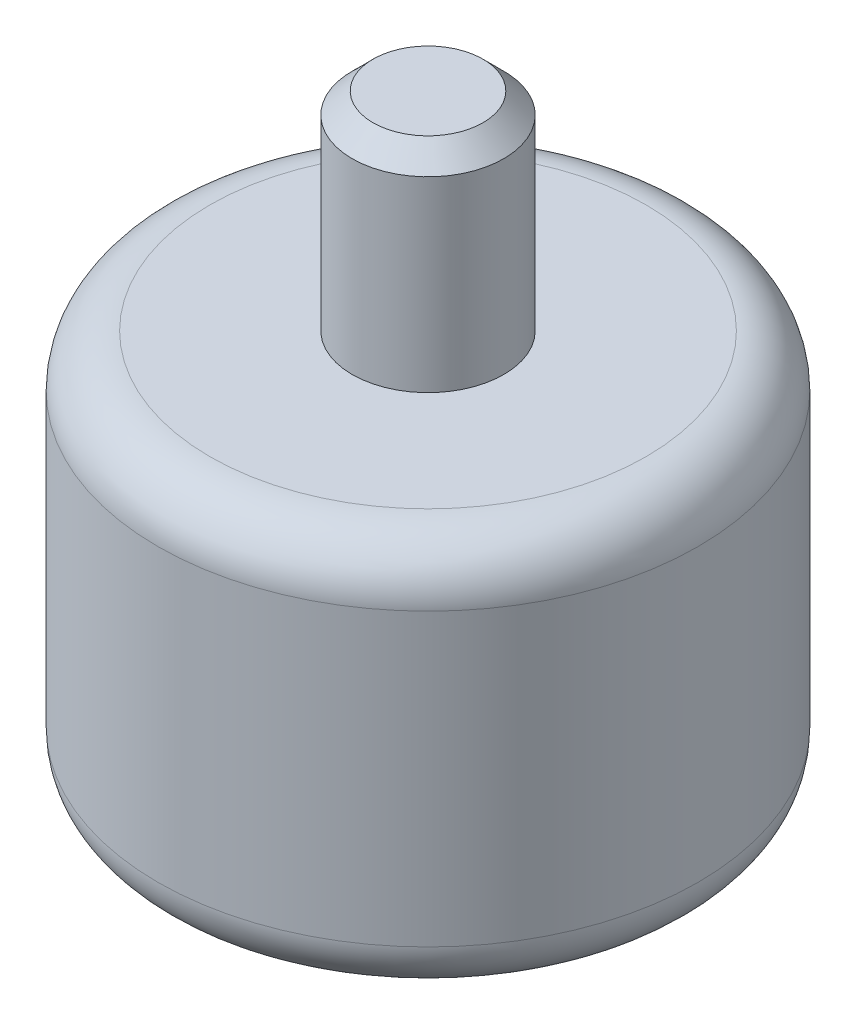
from build123d import *

# Parameters (mm, degrees)
SKETCH1_R             = 130
BOSS_EXTRUDE1_DEPTH   = 190
FILLET1_R             = 25
SKETCH2_R             = 36.5
BOSS_EXTRUDE2_DEPTH   = 20
M8_TAPPED_HOLE2_D     = 6.8
M8_TAPPED_HOLE2_DEPTH = 17.707073895
M8_TAPPED_HOLE2_TIP   = 2.042926105
SKETCH8_R             = 36.5
BOSS_EXTRUDE3_DEPTH   = 100
CHAMFER1_SIZE         = 10


with BuildPart() as part:
    # Sketch1 → Boss-Extrude1 (new body)
    with BuildSketch(Plane(origin=(0, 0, 0), x_dir=(1, 0, 0), z_dir=(0, 1, 0))):
        Circle(SKETCH1_R)
    extrude(amount=BOSS_EXTRUDE1_DEPTH)

    # Fillet1
    fillet1_edges = [part.edges().sort_by_distance(p)[0] for p in [
        (-130, 0, 0),
        (-130, 190, 0),
    ]]
    fillet(fillet1_edges, radius=FILLET1_R)

    # Sketch2 → Boss-Extrude2 (add)
    with BuildSketch(Plane.XZ):
        Circle(SKETCH2_R)
    extrude(amount=BOSS_EXTRUDE2_DEPTH)

    # M8 Tapped Hole2
    with Locations(Plane(origin=(0, 0, 0), x_dir=(-1, 0, 0), z_dir=(0, -1, 0))):
        with Locations((0, -95), (-95, 0), (0, 95), (95, 0)):
            Hole(M8_TAPPED_HOLE2_D / 2, depth=M8_TAPPED_HOLE2_DEPTH)
            with Locations((0, 0, -(M8_TAPPED_HOLE2_DEPTH + M8_TAPPED_HOLE2_TIP / 2))):  # 118° drill point
                Cone(0, M8_TAPPED_HOLE2_D / 2, M8_TAPPED_HOLE2_TIP, mode=Mode.SUBTRACT)

    # Sketch8 → Boss-Extrude3 (add)
    with BuildSketch(Plane(origin=(0, 190, 0), x_dir=(1, 0, 0), z_dir=(0, 1, 0))):
        Circle(SKETCH8_R)
    extrude(amount=BOSS_EXTRUDE3_DEPTH)

    # Chamfer1
    chamfer1_edges = [part.edges().sort_by_distance(p)[0] for p in [
        (-36.5, 290, 0),
    ]]
    chamfer(chamfer1_edges, length=CHAMFER1_SIZE)


solid = part.part
